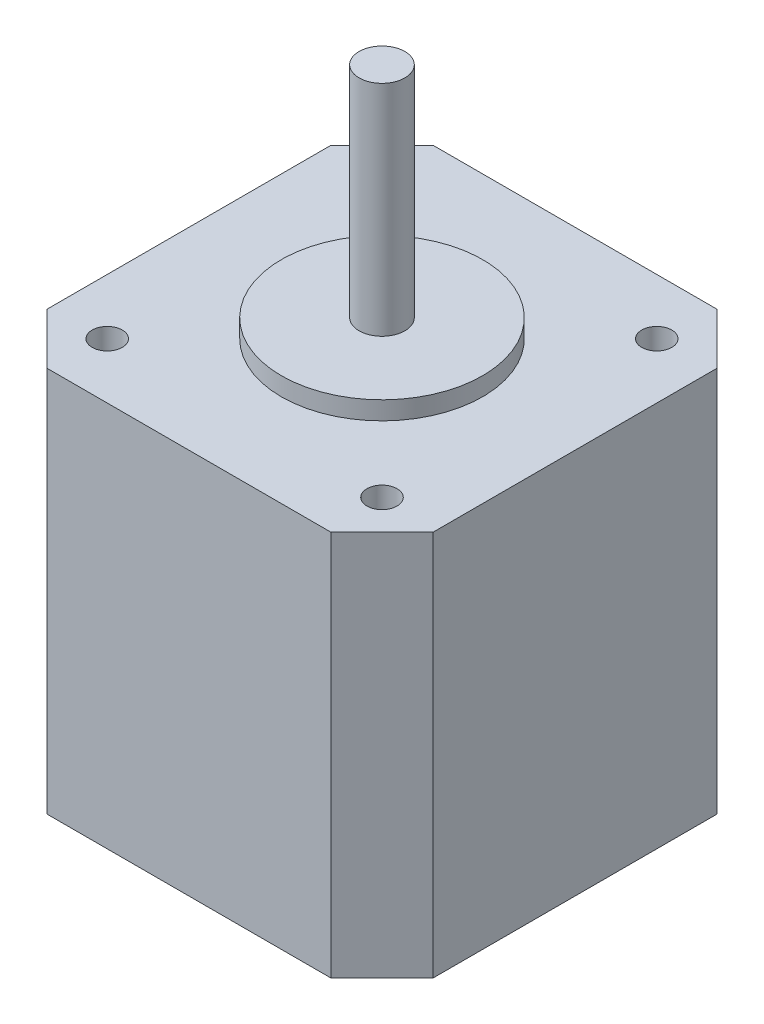
from build123d import *

# Parameters (mm, degrees)
ESBO_O1_W                = 42.3
ESBO_O1_H                = 42.3
RESSALTO_EXTRUS_O1_DEPTH = 21.15
ESBO_O2_R                = 11.025
RESSALTO_EXTRUS_O2_DEPTH = 2
ESBO_O3_R                = 2.506
RESSALTO_EXTRUS_O3_DEPTH = 24
CHANFRO1_SIZE            = 5.6
ESBO_O4_R                = 1.65
CORTE_EXTRUS_O1_DEPTH    = 10


with BuildPart() as part:
    # Esboço1 → Ressalto-extrusão1 (new body, symmetric)
    with BuildSketch(Plane(origin=(0, 0, 0), x_dir=(1, 0, 0), z_dir=(0, 1, 0))):
        Rectangle(ESBO_O1_W, ESBO_O1_H)
    extrude(amount=RESSALTO_EXTRUS_O1_DEPTH, both=True)

    # Esboço2 → Ressalto-extrusão2 (add)
    with BuildSketch(Plane(origin=(0, 21.15, 0), x_dir=(1, 0, 0), z_dir=(0, 1, 0))):
        Circle(ESBO_O2_R)
    extrude(amount=RESSALTO_EXTRUS_O2_DEPTH)

    # Esboço3 → Ressalto-extrusão3 (add)
    with BuildSketch(Plane(origin=(0, 23.15, 0), x_dir=(1, 0, 0), z_dir=(0, 1, 0))):
        Circle(ESBO_O3_R)
    extrude(amount=RESSALTO_EXTRUS_O3_DEPTH)

    # Chanfro1
    chanfro1_edges = [part.edges().sort_by_distance(p)[0] for p in [
        (21.15, 0, 21.15),
        (-21.15, 0, 21.15),
        (-21.15, 0, -21.15),
        (21.15, 0, -21.15),
    ]]
    chamfer(chanfro1_edges, length=CHANFRO1_SIZE)

    # Esboço4 → Corte-extrusão1 (cut)
    with BuildSketch(Plane(origin=(0, 21.15, 0), x_dir=(1, 0, 0), z_dir=(0, 1, 0))):
        with Locations((-15.05, 15.05)):
            Circle(ESBO_O4_R)
        with Locations((15.05, 15.05)):
            Circle(ESBO_O4_R)
        with Locations((15.05, -15.05)):
            Circle(ESBO_O4_R)
        with Locations((-15.05, -15.05)):
            Circle(ESBO_O4_R)
    extrude(amount=-CORTE_EXTRUS_O1_DEPTH, mode=Mode.SUBTRACT)


solid = part.part
